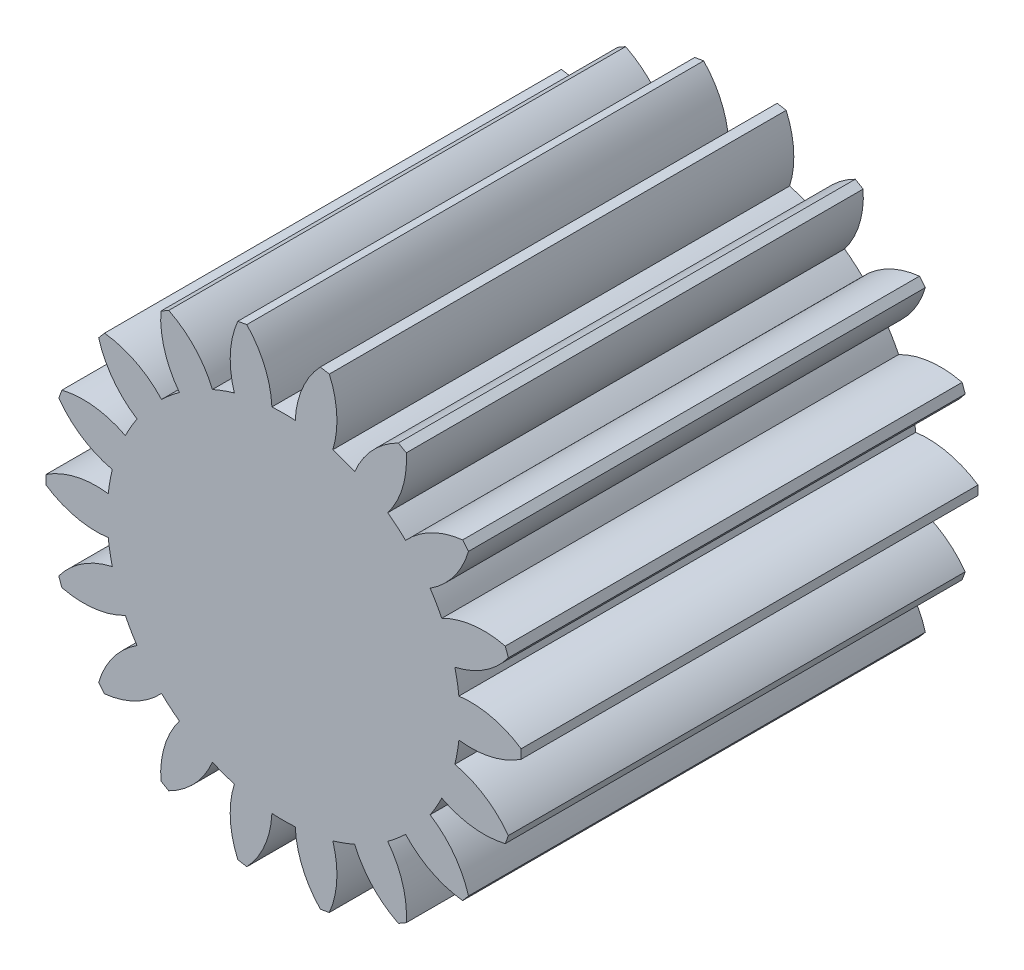
from build123d import *

# Parameters (mm, degrees)
BOSS_EXTRUDE1_DEPTH = 12.7
LARGER_TEETH_DEPTH  = 12.7
CUT_EXTRUDE1_START  = -2.54
SKETCH2_R           = 4.699
CUT_EXTRUDE1_DEPTH  = 10.16


with BuildPart() as part:
    # Sketch1 → Boss-Extrude1 (new body)
    with BuildSketch(Plane.XY):
        with BuildLine():
            ThreePointArc((4.073847183, 2.72678088), (4.623694629, 3.268673913), (4.961814921, 3.962687559))
            ThreePointArc((4.961814921, 3.962687559), (4.864382214, 4.081701322), (4.76409555, 4.19832033))
            ThreePointArc((4.76409555, 4.19832033), (4.021911558, 3.98585105), (3.392771091, 3.53845576))
            ThreePointArc((3.392771091, 3.53845576), (3.15107342, 3.755303069), (2.895550149, 3.955673669))
            ThreePointArc((2.895550149, 3.955673669), (3.226899403, 4.652945455), (3.3072619, 5.420748908))
            ThreePointArc((3.3072619, 5.420748908), (3.175, 5.499261314), (3.040875312, 5.574547276))
            ThreePointArc((3.040875312, 5.574547276), (2.416119265, 5.121049586), (1.977938812, 4.485456821))
            ThreePointArc((1.977938812, 4.485456821), (1.676651147, 4.606561166), (1.368007033, 4.707453834))
            ThreePointArc((1.368007033, 4.707453834), (1.440892486, 5.476003106), (1.253804284, 6.224987937))
            ThreePointArc((1.253804284, 6.224987937), (1.102665928, 6.253529232), (0.950880633, 6.27840155))
            ThreePointArc((0.950880633, 6.27840155), (0.518907331, 5.638573964), (0.324537921, 4.891445592))
            ThreePointArc((0.324537921, 4.891445592), (0, 4.9022), (-0.324537921, 4.891445592))
            ThreePointArc((-0.324537921, 4.891445592), (-0.518907331, 5.638573964), (-0.950880633, 6.27840155))
            ThreePointArc((-0.950880633, 6.27840155), (-1.102665928, 6.253529232), (-1.253804284, 6.224987937))
            ThreePointArc((-1.253804284, 6.224987937), (-1.440892486, 5.476003106), (-1.368007033, 4.707453834))
            ThreePointArc((-1.368007033, 4.707453834), (-1.676651147, 4.606561166), (-1.977938812, 4.485456821))
            ThreePointArc((-1.977938812, 4.485456821), (-2.416119265, 5.121049586), (-3.040875312, 5.574547276))
            ThreePointArc((-3.040875312, 5.574547276), (-3.175, 5.499261314), (-3.3072619, 5.420748908))
            ThreePointArc((-3.3072619, 5.420748908), (-3.226899403, 4.652945455), (-2.895550149, 3.955673669))
            ThreePointArc((-2.895550149, 3.955673669), (-3.15107342, 3.755303069), (-3.392771091, 3.53845576))
            ThreePointArc((-3.392771091, 3.53845576), (-4.021911558, 3.98585105), (-4.76409555, 4.19832033))
            ThreePointArc((-4.76409555, 4.19832033), (-4.864382214, 4.081701322), (-4.961814921, 3.962687559))
            ThreePointArc((-4.961814921, 3.962687559), (-4.623694629, 3.268673913), (-4.073847183, 2.72678088))
            ThreePointArc((-4.073847183, 2.72678088), (-4.245429734, 2.4511), (-4.398385104, 2.164664712))
            ThreePointArc((-4.398385104, 2.164664712), (-5.14260196, 2.369900051), (-5.912695554, 2.315713991))
            ThreePointArc((-5.912695554, 2.315713991), (-5.967048142, 2.17182791), (-6.017899834, 2.026667607))
            ThreePointArc((-6.017899834, 2.026667607), (-5.462804044, 1.490152056), (-4.760778124, 1.168998074))
            ThreePointArc((-4.760778124, 1.168998074), (-4.827724567, 0.851258097), (-4.873488961, 0.529783153))
            ThreePointArc((-4.873488961, 0.529783153), (-5.643018669, 0.468104131), (-6.348137212, 0.153798368))
            ThreePointArc((-6.348137212, 0.153798368), (-6.35, 0), (-6.348137212, -0.153798368))
            ThreePointArc((-6.348137212, -0.153798368), (-5.643018669, -0.468104131), (-4.873488961, -0.529783153))
            ThreePointArc((-4.873488961, -0.529783153), (-4.827724567, -0.851258097), (-4.760778124, -1.168998074))
            ThreePointArc((-4.760778124, -1.168998074), (-5.462804044, -1.490152056), (-6.017899834, -2.026667607))
            ThreePointArc((-6.017899834, -2.026667607), (-5.967048142, -2.17182791), (-5.912695554, -2.315713991))
            ThreePointArc((-5.912695554, -2.315713991), (-5.14260196, -2.369900051), (-4.398385104, -2.164664712))
            ThreePointArc((-4.398385104, -2.164664712), (-4.245429734, -2.4511), (-4.073847183, -2.72678088))
            ThreePointArc((-4.073847183, -2.72678088), (-4.623694629, -3.268673913), (-4.961814921, -3.962687559))
            ThreePointArc((-4.961814921, -3.962687559), (-4.864382214, -4.081701322), (-4.76409555, -4.19832033))
            ThreePointArc((-4.76409555, -4.19832033), (-4.021911558, -3.98585105), (-3.392771091, -3.53845576))
            ThreePointArc((-3.392771091, -3.53845576), (-3.15107342, -3.755303069), (-2.895550149, -3.955673669))
            ThreePointArc((-2.895550149, -3.955673669), (-3.226899403, -4.652945455), (-3.3072619, -5.420748908))
            ThreePointArc((-3.3072619, -5.420748908), (-3.175, -5.499261314), (-3.040875312, -5.574547276))
            ThreePointArc((-3.040875312, -5.574547276), (-2.416119265, -5.121049586), (-1.977938812, -4.485456821))
            ThreePointArc((-1.977938812, -4.485456821), (-1.676651147, -4.606561166), (-1.368007033, -4.707453834))
            ThreePointArc((-1.368007033, -4.707453834), (-1.440892486, -5.476003106), (-1.253804284, -6.224987937))
            ThreePointArc((-1.253804284, -6.224987937), (-1.102665928, -6.253529232), (-0.950880633, -6.27840155))
            ThreePointArc((-0.950880633, -6.27840155), (-0.518907331, -5.638573964), (-0.324537921, -4.891445592))
            ThreePointArc((-0.324537921, -4.891445592), (0, -4.9022), (0.324537921, -4.891445592))
            ThreePointArc((0.324537921, -4.891445592), (0.518907331, -5.638573964), (0.950880633, -6.27840155))
            ThreePointArc((0.950880633, -6.27840155), (1.102665928, -6.253529232), (1.253804284, -6.224987937))
            ThreePointArc((1.253804284, -6.224987937), (1.440892486, -5.476003106), (1.368007033, -4.707453834))
            ThreePointArc((1.368007033, -4.707453834), (1.676651147, -4.606561166), (1.977938812, -4.485456821))
            ThreePointArc((1.977938812, -4.485456821), (2.416119265, -5.121049586), (3.040875312, -5.574547276))
            ThreePointArc((3.040875312, -5.574547276), (3.175, -5.499261314), (3.3072619, -5.420748908))
            ThreePointArc((3.3072619, -5.420748908), (3.226899403, -4.652945455), (2.895550149, -3.955673669))
            ThreePointArc((2.895550149, -3.955673669), (3.15107342, -3.755303069), (3.392771091, -3.53845576))
            ThreePointArc((3.392771091, -3.53845576), (4.021911558, -3.98585105), (4.76409555, -4.19832033))
            ThreePointArc((4.76409555, -4.19832033), (4.864382214, -4.081701322), (4.961814921, -3.962687559))
            ThreePointArc((4.961814921, -3.962687559), (4.623694629, -3.268673913), (4.073847183, -2.72678088))
            ThreePointArc((4.073847183, -2.72678088), (4.245429734, -2.4511), (4.398385104, -2.164664712))
            ThreePointArc((4.398385104, -2.164664712), (5.14260196, -2.369900051), (5.912695554, -2.315713991))
            ThreePointArc((5.912695554, -2.315713991), (5.967048142, -2.17182791), (6.017899834, -2.026667607))
            ThreePointArc((6.017899834, -2.026667607), (5.462804044, -1.490152056), (4.760778124, -1.168998074))
            ThreePointArc((4.760778124, -1.168998074), (4.827724567, -0.851258097), (4.873488961, -0.529783153))
            ThreePointArc((4.873488961, -0.529783153), (5.643018669, -0.468104131), (6.348137212, -0.153798368))
            ThreePointArc((6.348137212, -0.153798368), (6.35, 0), (6.348137212, 0.153798368))
            ThreePointArc((6.348137212, 0.153798368), (5.643018669, 0.468104131), (4.873488961, 0.529783153))
            ThreePointArc((4.873488961, 0.529783153), (4.827724567, 0.851258097), (4.760778124, 1.168998074))
            ThreePointArc((4.760778124, 1.168998074), (5.462804044, 1.490152056), (6.017899834, 2.026667607))
            ThreePointArc((6.017899834, 2.026667607), (5.967048142, 2.17182791), (5.912695554, 2.315713991))
            ThreePointArc((5.912695554, 2.315713991), (5.14260196, 2.369900051), (4.398385104, 2.164664712))
            ThreePointArc((4.398385104, 2.164664712), (4.245429734, 2.4511), (4.073847183, 2.72678088))
        make_face()
    extrude(amount=-BOSS_EXTRUDE1_DEPTH)

    # Sketch3 → Larger_Teeth (add)
    with BuildSketch(Plane.XY):
        with BuildLine():
            Line((6.604, 0.127), (6.604, -0.127))
            ThreePointArc((6.604, -0.127), (5.775112058, -0.48464065), (4.873488961, -0.529783153))
            ThreePointArc((4.873488961, -0.529783153), (4.827724567, -0.851258097), (4.760778124, -1.168998074))
            ThreePointArc((4.760778124, -1.168998074), (5.592587049, -1.519791412), (6.249166626, -2.139360064))
            Line((6.249166626, -2.139360064), (6.162293509, -2.378041989))
            ThreePointArc((6.162293509, -2.378041989), (5.261073321, -2.430617896), (4.398385104, -2.164664712))
            ThreePointArc((4.398385104, -2.164664712), (4.245429734, -2.4511), (4.073847183, -2.72678088))
            ThreePointArc((4.073847183, -2.72678088), (4.735513505, -3.340914199), (5.140591529, -4.14768173))
            Line((5.140591529, -4.14768173), (4.977323476, -4.342257019))
            ThreePointArc((4.977323476, -4.342257019), (4.112471496, -4.083426752), (3.392771091, -3.53845576))
            ThreePointArc((3.392771091, -3.53845576), (3.15107342, -3.755303069), (2.895550149, -3.955673669))
            ThreePointArc((2.895550149, -3.955673669), (3.307267143, -4.759073427), (3.411985226, -5.655731767))
            Line((3.411985226, -5.655731767), (3.192014774, -5.782731767))
            ThreePointArc((3.192014774, -5.782731767), (2.467844915, -5.243714077), (1.977938812, -4.485456821))
            ThreePointArc((1.977938812, -4.485456821), (1.676651147, -4.606561166), (1.368007033, -4.707453834))
            ThreePointArc((1.368007033, -4.707453834), (1.480115554, -5.603218164), (1.27184315, -6.481617082))
            Line((1.27184315, -6.481617082), (1.021701981, -6.525723719))
            ThreePointArc((1.021701981, -6.525723719), (0.525559816, -5.771532095), (0.324537921, -4.891445592))
            ThreePointArc((0.324537921, -4.891445592), (0, -4.9022), (-0.324537921, -4.891445592))
            ThreePointArc((-0.324537921, -4.891445592), (-0.525559816, -5.771532095), (-1.021701981, -6.525723719))
            Line((-1.021701981, -6.525723719), (-1.27184315, -6.481617082))
            ThreePointArc((-1.27184315, -6.481617082), (-1.480115554, -5.603218164), (-1.368007033, -4.707453834))
            ThreePointArc((-1.368007033, -4.707453834), (-1.676651147, -4.606561166), (-1.977938812, -4.485456821))
            ThreePointArc((-1.977938812, -4.485456821), (-2.467844915, -5.243714077), (-3.192014774, -5.782731767))
            Line((-3.192014774, -5.782731767), (-3.411985226, -5.655731767))
            ThreePointArc((-3.411985226, -5.655731767), (-3.307267143, -4.759073427), (-2.895550149, -3.955673669))
            ThreePointArc((-2.895550149, -3.955673669), (-3.15107342, -3.755303069), (-3.392771091, -3.53845576))
            ThreePointArc((-3.392771091, -3.53845576), (-4.112471496, -4.083426752), (-4.977323476, -4.342257019))
            Line((-4.977323476, -4.342257019), (-5.140591529, -4.14768173))
            ThreePointArc((-5.140591529, -4.14768173), (-4.735513505, -3.340914199), (-4.073847183, -2.72678088))
            ThreePointArc((-4.073847183, -2.72678088), (-4.245429734, -2.4511), (-4.398385104, -2.164664712))
            ThreePointArc((-4.398385104, -2.164664712), (-5.261073321, -2.430617896), (-6.162293509, -2.378041989))
            Line((-6.162293509, -2.378041989), (-6.249166626, -2.139360064))
            ThreePointArc((-6.249166626, -2.139360064), (-5.592587049, -1.519791412), (-4.760778124, -1.168998074))
            ThreePointArc((-4.760778124, -1.168998074), (-4.827724567, -0.851258097), (-4.873488961, -0.529783153))
            ThreePointArc((-4.873488961, -0.529783153), (-5.775112058, -0.48464065), (-6.604, -0.127))
            Line((-6.604, -0.127), (-6.604, 0.127))
            ThreePointArc((-6.604, 0.127), (-5.775112058, 0.48464065), (-4.873488961, 0.529783153))
            ThreePointArc((-4.873488961, 0.529783153), (-4.827724567, 0.851258097), (-4.760778124, 1.168998074))
            ThreePointArc((-4.760778124, 1.168998074), (-5.592587049, 1.519791412), (-6.249166626, 2.139360064))
            Line((-6.249166626, 2.139360064), (-6.162293509, 2.378041989))
            ThreePointArc((-6.162293509, 2.378041989), (-5.261073321, 2.430617896), (-4.398385104, 2.164664712))
            ThreePointArc((-4.398385104, 2.164664712), (-4.245429734, 2.4511), (-4.073847183, 2.72678088))
            ThreePointArc((-4.073847183, 2.72678088), (-4.735513505, 3.340914199), (-5.140591529, 4.14768173))
            Line((-5.140591529, 4.14768173), (-4.977323476, 4.342257019))
            ThreePointArc((-4.977323476, 4.342257019), (-4.112471496, 4.083426752), (-3.392771091, 3.53845576))
            ThreePointArc((-3.392771091, 3.53845576), (-3.15107342, 3.755303069), (-2.895550149, 3.955673669))
            ThreePointArc((-2.895550149, 3.955673669), (-3.307267143, 4.759073427), (-3.411985226, 5.655731767))
            Line((-3.411985226, 5.655731767), (-3.192014774, 5.782731767))
            ThreePointArc((-3.192014774, 5.782731767), (-2.467844915, 5.243714077), (-1.977938812, 4.485456821))
            ThreePointArc((-1.977938812, 4.485456821), (-1.676651147, 4.606561166), (-1.368007033, 4.707453834))
            ThreePointArc((-1.368007033, 4.707453834), (-1.480115554, 5.603218164), (-1.27184315, 6.481617082))
            Line((-1.27184315, 6.481617082), (-1.021701981, 6.525723719))
            ThreePointArc((-1.021701981, 6.525723719), (-0.525559816, 5.771532095), (-0.324537921, 4.891445592))
            ThreePointArc((-0.324537921, 4.891445592), (0, 4.9022), (0.324537921, 4.891445592))
            ThreePointArc((0.324537921, 4.891445592), (0.525559816, 5.771532095), (1.021701981, 6.525723719))
            Line((1.021701981, 6.525723719), (1.27184315, 6.481617082))
            ThreePointArc((1.27184315, 6.481617082), (1.480115554, 5.603218164), (1.368007033, 4.707453834))
            ThreePointArc((1.368007033, 4.707453834), (1.676651147, 4.606561166), (1.977938812, 4.485456821))
            ThreePointArc((1.977938812, 4.485456821), (2.467844915, 5.243714077), (3.192014774, 5.782731767))
            Line((3.192014774, 5.782731767), (3.411985226, 5.655731767))
            ThreePointArc((3.411985226, 5.655731767), (3.307267143, 4.759073427), (2.895550149, 3.955673669))
            ThreePointArc((2.895550149, 3.955673669), (3.15107342, 3.755303069), (3.392771091, 3.53845576))
            ThreePointArc((3.392771091, 3.53845576), (4.112471496, 4.083426752), (4.977323476, 4.342257019))
            Line((4.977323476, 4.342257019), (5.140591529, 4.14768173))
            ThreePointArc((5.140591529, 4.14768173), (4.735513505, 3.340914199), (4.073847183, 2.72678088))
            ThreePointArc((4.073847183, 2.72678088), (4.245429734, 2.4511), (4.398385104, 2.164664712))
            ThreePointArc((4.398385104, 2.164664712), (5.261073321, 2.430617896), (6.162293509, 2.378041989))
            Line((6.162293509, 2.378041989), (6.249166626, 2.139360064))
            ThreePointArc((6.249166626, 2.139360064), (5.592587049, 1.519791412), (4.760778124, 1.168998074))
            ThreePointArc((4.760778124, 1.168998074), (4.827724567, 0.851258097), (4.873488961, 0.529783153))
            ThreePointArc((4.873488961, 0.529783153), (5.775112058, 0.48464065), (6.604, 0.127))
        make_face()
    extrude(amount=-LARGER_TEETH_DEPTH)

    # Sketch2 → Cut-Extrude1 (cut)
    with BuildSketch(Plane.XY.offset(CUT_EXTRUDE1_START)):
        Circle(SKETCH2_R)
    extrude(amount=-CUT_EXTRUDE1_DEPTH, mode=Mode.SUBTRACT)


solid = part.part
